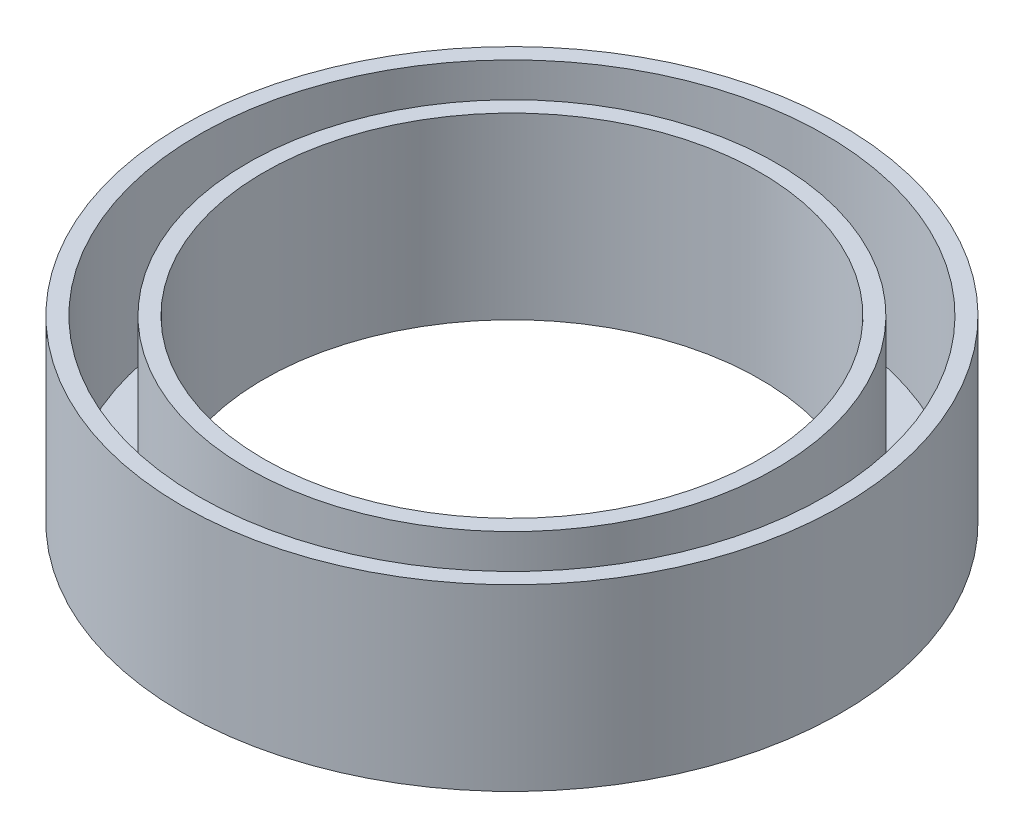
from build123d import *

# Parameters (mm, degrees)
SKETCH_1_R           = 19.25
SKETCH_1_R_2         = 16.25
EXTRUDE_1_DEPTH      = 1
SKETCH_3_R           = 20.25
SKETCH_3_R_2         = 19.25
SKETCH_3_R_3         = 16.25
SKETCH_3_R_4         = 15.25
EXTRUDE_3_DEPTH      = 10
EXTRUDE_3_DEPTH_BACK = 1


with BuildPart() as part:
    # 草图1 → 凸台-拉伸1 (new body)
    with BuildSketch(Plane(origin=(0, 0, 0), x_dir=(1, 0, 0), z_dir=(0, 1, 0))):
        Circle(SKETCH_1_R)
        Circle(SKETCH_1_R_2, mode=Mode.SUBTRACT)
    extrude(amount=EXTRUDE_1_DEPTH)

    # 草图3 → 凸台-拉伸3 (add, two sides)
    with BuildSketch(Plane(origin=(0, 1, 0), x_dir=(1, 0, 0), z_dir=(0, 1, 0))) as extrude_3_sk:
        Circle(SKETCH_3_R)
        Circle(SKETCH_3_R_2, mode=Mode.SUBTRACT)
        Circle(SKETCH_3_R_3)
        Circle(SKETCH_3_R_4, mode=Mode.SUBTRACT)
    extrude(amount=EXTRUDE_3_DEPTH)
    extrude(extrude_3_sk.sketch, amount=-EXTRUDE_3_DEPTH_BACK)


solid = part.part
